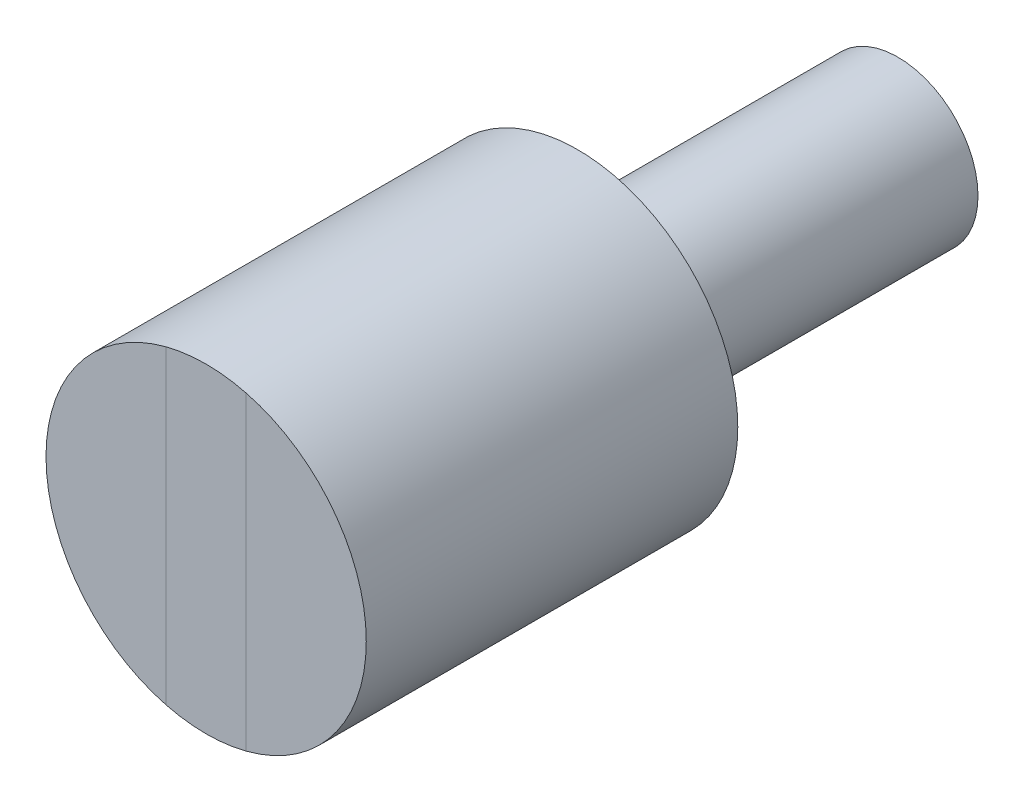
from build123d import *

# Parameters (mm, degrees)
SKETCH1_LINK6_R     = 15
BOSS_EXTRUDE1_DEPTH = 30
SKETCH2_LINK6_R     = 30
BOSS_EXTRUDE2_DEPTH = 69.6
BOSS_EXTRUDE3_DEPTH = 0.001


with BuildPart() as part:
    # sketch1_link6 → Boss-Extrude1 (new body, symmetric)
    with BuildSketch(Plane.XY):
        Circle(SKETCH1_LINK6_R)
    extrude(amount=BOSS_EXTRUDE1_DEPTH, both=True)

    # sketch2_link6 → Boss-Extrude2 (add)
    with BuildSketch(Plane.XY.offset(30)):
        Circle(SKETCH2_LINK6_R)
    extrude(amount=BOSS_EXTRUDE2_DEPTH)

    # sketch3_link6 → Boss-Extrude3 (add)
    with BuildSketch(Plane.XY.offset(99.6)):
        with BuildLine():
            Line((-7.5, 29.047375097), (-7.5, -29.047375097))
            ThreePointArc((-7.5, -29.047375097), (0, -30), (7.5, -29.047375097))
            Line((7.5, -29.047375097), (7.5, 29.047375097))
            ThreePointArc((7.5, 29.047375097), (0, 30), (-7.5, 29.047375097))
        make_face()
    extrude(amount=BOSS_EXTRUDE3_DEPTH)


solid = part.part
